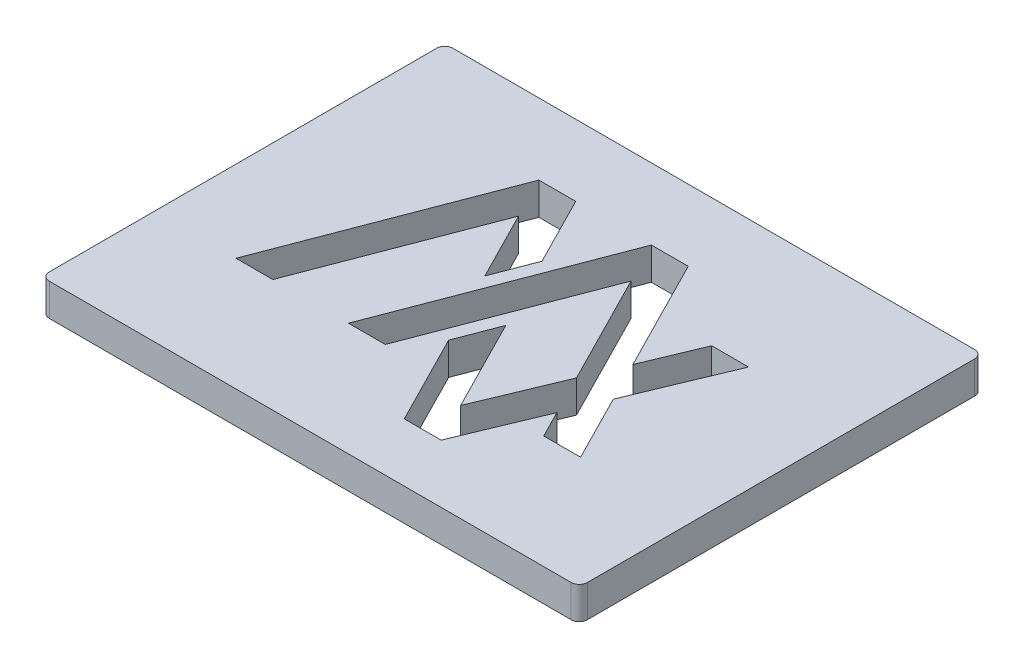
from build123d import *

# Parameters (mm, degrees)
BOSS_EXTRUDE1_DEPTH = 12
CUT_EXTRUDE1_DEPTH  = 12


with BuildPart() as part:
    # Sketch1 → Boss-Extrude1 (new body)
    with BuildSketch(Plane(origin=(0, 0, 0), x_dir=(1, 0, 0), z_dir=(0, 1, 0))):
        with BuildLine():
            Line((-97, -75), (97, -75))
            ThreePointArc((97, -75), (99.121320344, -74.121320344), (100, -72))
            Line((100, -72), (100, 72))
            ThreePointArc((100, 72), (99.121320344, 74.121320344), (97, 75))
            Line((97, 75), (-97, 75))
            ThreePointArc((-97, 75), (-99.121320344, 74.121320344), (-100, 72))
            Line((-100, 72), (-100, -72))
            ThreePointArc((-100, -72), (-99.121320344, -74.121320344), (-97, -75))
        make_face()
    extrude(amount=BOSS_EXTRUDE1_DEPTH)

    # Sketch2 → Cut-Extrude1 (cut)
    with BuildSketch(Plane(origin=(0, 12, 0), x_dir=(1, 0, 0), z_dir=(0, 1, 0))):
        Polygon((-24.855906811, 48.549939904), (-11.856976443, 23.007043942), (-17.732961605, 7.632856116), (-30.731891973, 33.175752078), (-55.995225818, -32.924353512), (-69.695225818, -32.924353512), (-38.555906811, 48.549939904), align=None)
        Polygon((45.817241453, -8.158042149), (58.420963339, -32.924353512), (44.720963339, -32.924353512), (39.651548235, -22.962953695), (26.998770847, -53.344492874), (13.298770847, -53.344492874), (-3.795083958, -19.755071091), (2.080901204, -4.380883265), (19.464464064, -38.539581328), (32.117241453, -8.158042149), (11.082229848, 33.175752078), (-14.181103997, -32.924353512), (-27.881103997, -32.924353512), (3.25821501, 48.549939904), (16.95821501, 48.549939904), (38.28293467, 6.646869398), (46.899276911, 27.336219357), (60.599276911, 27.336219357), align=None)
    extrude(amount=-CUT_EXTRUDE1_DEPTH, mode=Mode.SUBTRACT)


solid = part.part
